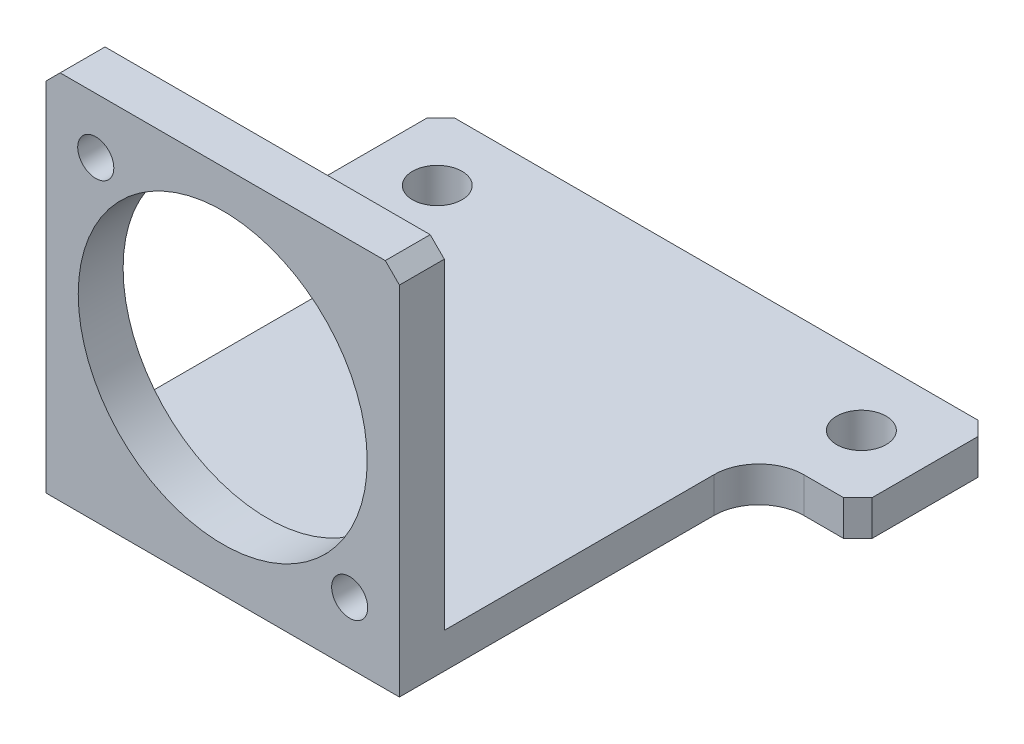
from build123d import *

# Parameters (mm, degrees)
SKETCH1_W                  = 50
SKETCH1_H                  = 52.48
SKETCH1_R                  = 20.44
BOSS_EXTRUDE1_DEPTH        = 6.35
SKETCH4_R                  = 3.5
BOSS_EXTRUDE4_DEPTH        = 5
F_10_CLEARANCE_HOLE1_D     = 5.1054
F_10_CLEARANCE_HOLE1_DEPTH = 6.35
FILLET1_R                  = 6.35
CHAMFER1_SIZE              = 2
CHAMFER2_SIZE              = 2


with BuildPart() as part:
    # Sketch1 → Boss-Extrude1 (new body)
    with BuildSketch(Plane.XY):
        Rectangle(SKETCH1_W, SKETCH1_H)
        with Locations((0, 0.415)):
            Circle(SKETCH1_R, mode=Mode.SUBTRACT)
    extrude(amount=BOSS_EXTRUDE1_DEPTH)

    # Sketch4 → Boss-Extrude4 (add)
    with BuildSketch(Plane.XZ.offset(26.24)):
        Polygon((25, -44.5), (25, 0), (-25, 0), (-25, -44.5), (-39, -44.5), (-39, -63.5), (39, -63.5), (39, -44.5), align=None)
        with Locations((30, -54)):
            Circle(SKETCH4_R, mode=Mode.SUBTRACT)
        with Locations((-30, -54)):
            Circle(SKETCH4_R, mode=Mode.SUBTRACT)
    extrude(amount=-BOSS_EXTRUDE4_DEPTH)

    # #10 Clearance Hole1
    with Locations(Plane.XY.offset(6.35)):
        with Locations((17.960512242, -17.545512242), (-17.960512242, 18.375512242)):
            Hole(F_10_CLEARANCE_HOLE1_D / 2, depth=F_10_CLEARANCE_HOLE1_DEPTH)

    # Fillet1
    fillet1_edges = [part.edges().sort_by_distance(p)[0] for p in [
        (-25, -23.74, -44.5),
        (25, -23.74, -44.5),
    ]]
    fillet(fillet1_edges, radius=FILLET1_R)

    # Chamfer1
    chamfer1_edges = [part.edges().sort_by_distance(p)[0] for p in [
        (39, -23.74, -44.5),
        (39, -23.74, -63.5),
        (-39, -23.74, -63.5),
        (-39, -23.74, -44.5),
    ]]
    chamfer(chamfer1_edges, length=CHAMFER1_SIZE)

    # Chamfer2
    chamfer2_edges = [part.edges().sort_by_distance(p)[0] for p in [
        (-25, 26.24, 3.175),
        (25, 26.24, 3.175),
    ]]
    chamfer(chamfer2_edges, length=CHAMFER2_SIZE)


solid = part.part
